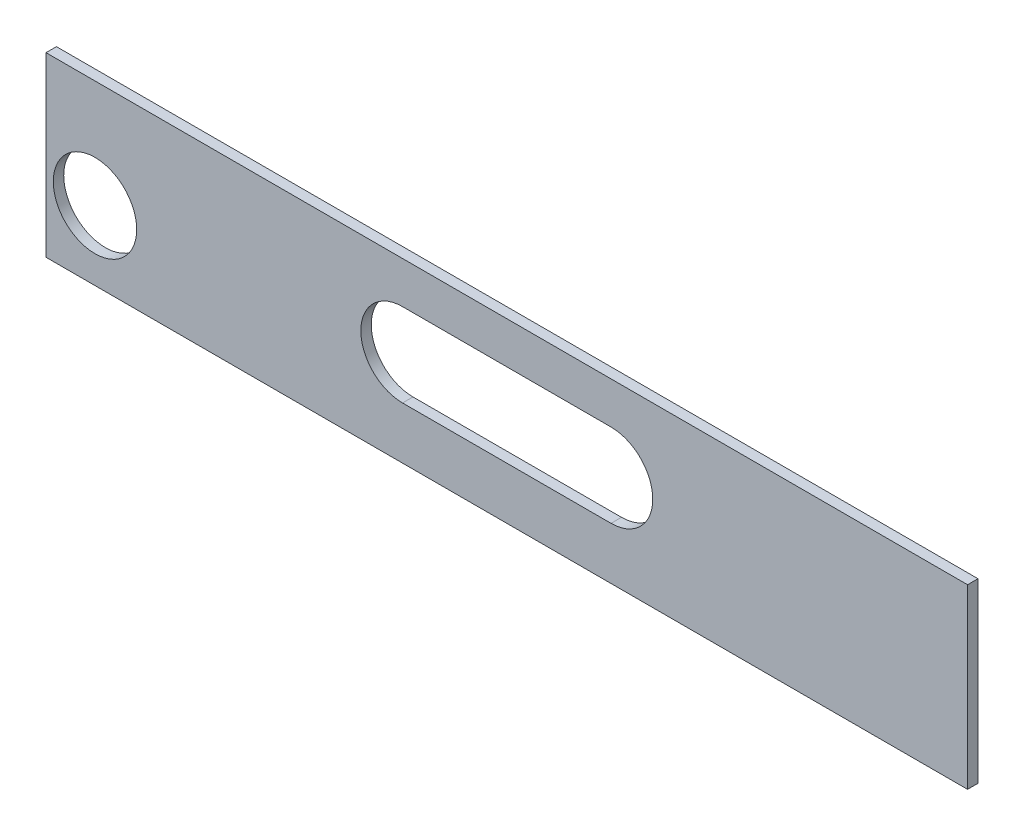
from build123d import *

# Parameters (mm, degrees)
SKETCH1_W           = 88.4
SKETCH1_H           = 17
BOSS_EXTRUDE1_DEPTH = 1
SKETCH_1_R          = 4
CUT_EXTRUDE_1_DEPTH = 10


with BuildPart() as part:
    # Sketch1 → Boss-Extrude1 (new body)
    with BuildSketch(Plane.XY):
        with Locations((2.05547482, -11.135386556)):
            Rectangle(SKETCH1_W, SKETCH1_H)
    extrude(amount=BOSS_EXTRUDE1_DEPTH)

    # ｽｹｯﾁ1 → ｶｯﾄ - 押し出し1 (cut)
    with BuildSketch(Plane(origin=(0, 0, 0), x_dir=(-1, 0, 0), z_dir=(0, 0, -1))):
        with Locations((37.44452518, -12.985386556)):
            Circle(SKETCH_1_R)
        with BuildLine():
            Line((-12.05547482, -6.635386556), (7.94452518, -6.635386556))
            ThreePointArc((7.94452518, -6.635386556), (11.94452518, -10.635386556), (7.94452518, -14.635386556))
            Line((7.94452518, -14.635386556), (-12.05547482, -14.635386556))
            ThreePointArc((-12.05547482, -14.635386556), (-16.05547482, -10.635386556), (-12.05547482, -6.635386556))
        make_face()
    extrude(amount=-CUT_EXTRUDE_1_DEPTH, mode=Mode.SUBTRACT)


solid = part.part
